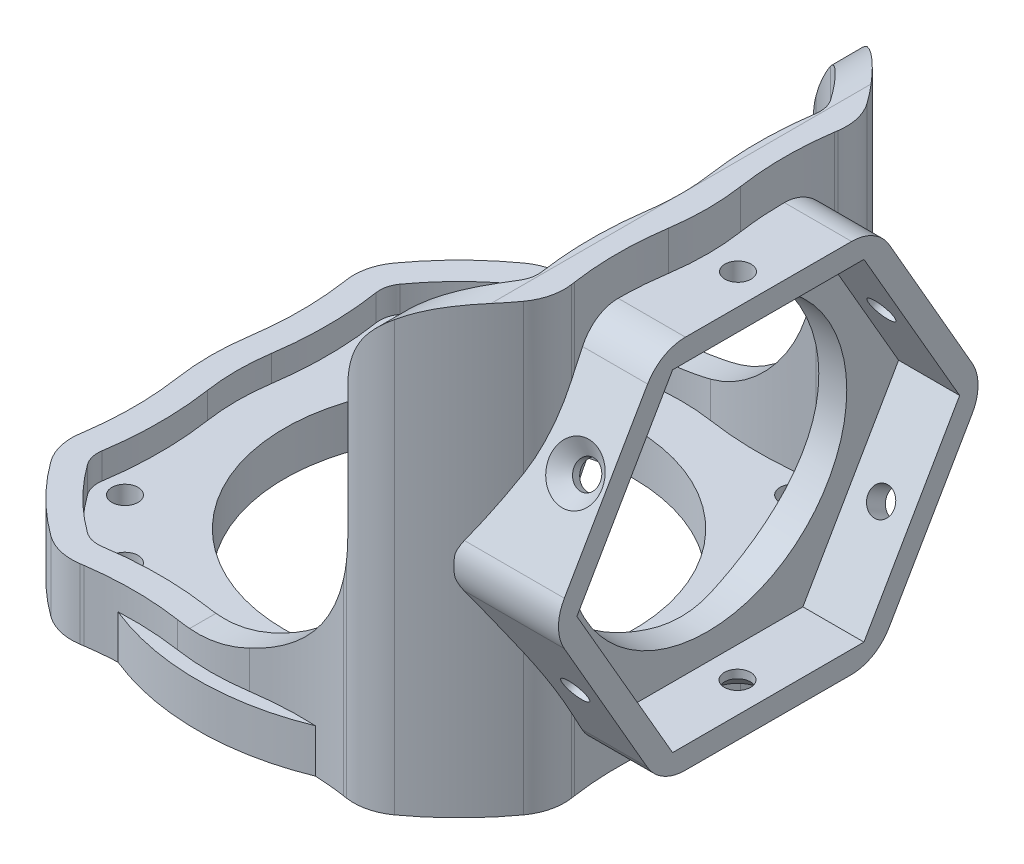
from build123d import *
from build123d.topology import SkipClean

# Parameters (mm, degrees)
SKETCH_1_R               = 30
SKETCH_1_R_2             = 20
SKETCH_1_R_3             = 1.5
EXTRUDE_1_DEPTH          = 5
EXTRUDE_2_DEPTH          = 46
EXTRUDE_2_DEPTH_BACK     = 5
CUT_EXTRUDE_1_DEPTH      = 67.340033162
CUT_EXTRUDE_1_DEPTH_BACK = 67.340033162
CUT_EXTRUDE_2_DEPTH      = 19
CUT_EXTRUDE_2_DEPTH_BACK = 22
SKETCH_4_R               = 16
CUT_EXTRUDE_3_DEPTH      = 67.340033239
EXTRUDE_4_DEPTH          = 7
EXTRUDE_4_DEPTH_BACK     = 5
SKETCH_5_R               = 16
CUT_EXTRUDE_4_REACH      = 70.976
CUT_EXTRUDE_5_DEPTH      = 7
SKETCH_10_R              = 1.5
CUT_EXTRUDE_6_DEPTH      = 78.090718091
SKETCH_11_R              = 1.5
CUT_EXTRUDE_7_DEPTH      = 76.948521446
SKETCH_12_R              = 1.5
CUT_EXTRUDE_8_DEPTH      = 67.432206651
EXTRUDE_5_DEPTH          = 5
CHAMFER_1_SIZE           = 1.55


with BuildPart() as part:
    # 草图1 → 凸台-拉伸1 (new body)
    with BuildSketch(Plane(origin=(0, 0, 0), x_dir=(1, 0, 0), z_dir=(0, 1, 0))):
        with Locations(Location((0, 0, 0), (0, 0, 270))):
            Circle(SKETCH_1_R)
        with Locations(Location((0, 0, 0), (0, 0, 270))):
            Circle(SKETCH_1_R_2, mode=Mode.SUBTRACT)
        with Locations(Location((-22.526681218, 15.773352, 0), (0, 0, 270))):
            Circle(SKETCH_1_R_3, mode=Mode.SUBTRACT)
        with Locations(Location((-15.773352, 22.526681218, 0), (0, 0, 270))):
            Circle(SKETCH_1_R_3, mode=Mode.SUBTRACT)
        with Locations(Location((22.526681218, 15.773352, 0), (0, 0, 90))):
            Circle(SKETCH_1_R_3, mode=Mode.SUBTRACT)
        with Locations(Location((15.773352, 22.526681218, 0), (0, 0, 90))):
            Circle(SKETCH_1_R_3, mode=Mode.SUBTRACT)
        with Locations(Location((22.526681218, -15.773352, 0), (0, 0, 270))):
            Circle(SKETCH_1_R_3, mode=Mode.SUBTRACT)
        with Locations(Location((15.773352, -22.526681218, 0), (0, 0, 270))):
            Circle(SKETCH_1_R_3, mode=Mode.SUBTRACT)
        with Locations(Location((-22.526681218, -15.773352, 0), (0, 0, 90))):
            Circle(SKETCH_1_R_3, mode=Mode.SUBTRACT)
        with Locations(Location((-15.773352, -22.526681218, 0), (0, 0, 90))):
            Circle(SKETCH_1_R_3, mode=Mode.SUBTRACT)
    extrude(amount=EXTRUDE_1_DEPTH)

    # 草图2 → 凸台-拉伸2 (add, two sides: drawn at the far end of the back side and taken through both)
    with BuildSketch(Plane(origin=(0, 5, 0), x_dir=(1, 0, 0), z_dir=(0, 1, 0)).offset(-EXTRUDE_2_DEPTH_BACK)):
        with BuildLine():
            ThreePointArc((28.144567873, 4.120724104), (28.45, 0), (28.144567873, -4.120724104))
            ThreePointArc((28.144567873, -4.120724104), (27.740305816, -9.505453332), (28.124116302, -14.891678929))
            ThreePointArc((28.124116302, -14.891678929), (28.151905564, -15.079780205), (28.180635292, -15.267740136))
            ThreePointArc((28.180635292, -15.267740136), (28.077159321, -17.585544722), (27.102069312, -19.690805952))
            ThreePointArc((27.102069312, -19.690805952), (23.68807717, -23.68807717), (19.690805952, -27.102069312))
            ThreePointArc((19.690805952, -27.102069312), (17.585544722, -28.077159321), (15.267740136, -28.180635292))
            ThreePointArc((15.267740136, -28.180635292), (15.079780205, -28.151905564), (14.891678929, -28.124116302))
            ThreePointArc((14.891678929, -28.124116302), (9.505453332, -27.740305816), (4.120724104, -28.144567873))
            ThreePointArc((4.120724104, -28.144567873), (0, -28.45), (-4.120724104, -28.144567873))
            ThreePointArc((-4.120724104, -28.144567873), (-9.505453332, -27.740305816), (-14.891678929, -28.124116302))
            ThreePointArc((-14.891678929, -28.124116302), (-15.079780205, -28.151905564), (-15.267740136, -28.180635292))
            ThreePointArc((-15.267740136, -28.180635292), (-17.585544722, -28.077159321), (-19.690805952, -27.102069312))
            ThreePointArc((-19.690805952, -27.102069312), (-23.68807717, -23.68807717), (-27.102069312, -19.690805952))
            ThreePointArc((-27.102069312, -19.690805952), (-28.077159321, -17.585544722), (-28.180635292, -15.267740136))
            ThreePointArc((-28.180635292, -15.267740136), (-28.151905564, -15.079780205), (-28.124116302, -14.891678929))
            ThreePointArc((-28.124116302, -14.891678929), (-27.740305816, -9.505453332), (-28.144567873, -4.120724104))
            ThreePointArc((-28.144567873, -4.120724104), (-28.45, 0), (-28.144567873, 4.120724104))
            ThreePointArc((-28.144567873, 4.120724104), (-27.740305816, 9.505453332), (-28.124116302, 14.891678929))
            ThreePointArc((-28.124116302, 14.891678929), (-28.151905564, 15.079780205), (-28.180635292, 15.267740136))
            ThreePointArc((-28.180635292, 15.267740136), (-28.077159321, 17.585544722), (-27.102069312, 19.690805952))
            ThreePointArc((-27.102069312, 19.690805952), (-23.68807717, 23.68807717), (-19.690805952, 27.102069312))
            ThreePointArc((-19.690805952, 27.102069312), (-17.585544722, 28.077159321), (-15.267740136, 28.180635292))
            ThreePointArc((-15.267740136, 28.180635292), (-15.079780205, 28.151905564), (-14.891678929, 28.124116302))
            ThreePointArc((-14.891678929, 28.124116302), (-9.505453332, 27.740305816), (-4.120724104, 28.144567873))
            ThreePointArc((-4.120724104, 28.144567873), (0, 28.45), (4.120724104, 28.144567873))
            ThreePointArc((4.120724104, 28.144567873), (9.505453332, 27.740305816), (14.891678929, 28.124116302))
            ThreePointArc((14.891678929, 28.124116302), (15.079780205, 28.151905564), (15.267740136, 28.180635292))
            ThreePointArc((15.267740136, 28.180635292), (17.585544722, 28.077159321), (19.690805952, 27.102069312))
            ThreePointArc((19.690805952, 27.102069312), (23.68807717, 23.68807717), (27.102069312, 19.690805952))
            ThreePointArc((27.102069312, 19.690805952), (28.077159321, 17.585544722), (28.180635292, 15.267740136))
            ThreePointArc((28.180635292, 15.267740136), (28.151905564, 15.079780205), (28.124116302, 14.891678929))
            ThreePointArc((28.124116302, 14.891678929), (27.740305816, 9.505453332), (28.144567873, 4.120724104))
        make_face()
        with BuildLine():
            ThreePointArc((25.177351285, -3.678428135), (25.45, 0), (25.177351285, 3.678428135))
            ThreePointArc((25.177351285, 3.678428135), (24.910544975, 5.888504903), (24.767101806, 8.110001917))
            ThreePointArc((24.767101806, 8.110001917), (24.808867462, 11.917834471), (25.212544446, 15.70443955))
            ThreePointArc((25.212544446, 15.70443955), (25.163933297, 16.869177817), (24.675018328, 17.927450195))
            ThreePointArc((24.675018328, 17.927450195), (21.566756826, 21.566756826), (17.927450195, 24.675018328))
            ThreePointArc((17.927450195, 24.675018328), (16.869177817, 25.163933297), (15.70443955, 25.212544446))
            ThreePointArc((15.70443955, 25.212544446), (11.917834471, 24.808867462), (8.110001917, 24.767101806))
            ThreePointArc((8.110001917, 24.767101806), (5.888504903, 24.910544975), (3.678428135, 25.177351285))
            ThreePointArc((3.678428135, 25.177351285), (0, 25.45), (-3.678428135, 25.177351285))
            ThreePointArc((-3.678428135, 25.177351285), (-5.888504903, 24.910544975), (-8.110001917, 24.767101806))
            ThreePointArc((-8.110001917, 24.767101806), (-11.917834471, 24.808867462), (-15.70443955, 25.212544446))
            ThreePointArc((-15.70443955, 25.212544446), (-16.869177817, 25.163933297), (-17.927450195, 24.675018328))
            ThreePointArc((-17.927450195, 24.675018328), (-21.566756826, 21.566756826), (-24.675018328, 17.927450195))
            ThreePointArc((-24.675018328, 17.927450195), (-25.163933297, 16.869177817), (-25.212544446, 15.70443955))
            ThreePointArc((-25.212544446, 15.70443955), (-24.808867462, 11.917834471), (-24.767101806, 8.110001917))
            ThreePointArc((-24.767101806, 8.110001917), (-24.910544975, 5.888504903), (-25.177351285, 3.678428135))
            ThreePointArc((-25.177351285, 3.678428135), (-25.45, 0), (-25.177351285, -3.678428135))
            ThreePointArc((-25.177351285, -3.678428135), (-24.910544975, -5.888504903), (-24.767101806, -8.110001917))
            ThreePointArc((-24.767101806, -8.110001917), (-24.808867462, -11.917834471), (-25.212544446, -15.70443955))
            ThreePointArc((-25.212544446, -15.70443955), (-25.163933297, -16.869177817), (-24.675018328, -17.927450195))
            ThreePointArc((-24.675018328, -17.927450195), (-21.566756826, -21.566756826), (-17.927450195, -24.675018328))
            ThreePointArc((-17.927450195, -24.675018328), (-16.869177817, -25.163933297), (-15.70443955, -25.212544446))
            ThreePointArc((-15.70443955, -25.212544446), (-11.917834471, -24.808867462), (-8.110001917, -24.767101806))
            ThreePointArc((-8.110001917, -24.767101806), (-5.888504903, -24.910544975), (-3.678428135, -25.177351285))
            ThreePointArc((-3.678428135, -25.177351285), (0, -25.45), (3.678428135, -25.177351285))
            ThreePointArc((3.678428135, -25.177351285), (5.888504903, -24.910544975), (8.110001917, -24.767101806))
            ThreePointArc((8.110001917, -24.767101806), (11.917834471, -24.808867462), (15.70443955, -25.212544446))
            ThreePointArc((15.70443955, -25.212544446), (16.869177817, -25.163933297), (17.927450195, -24.675018328))
            ThreePointArc((17.927450195, -24.675018328), (21.566756826, -21.566756826), (24.675018328, -17.927450195))
            ThreePointArc((24.675018328, -17.927450195), (25.163933297, -16.869177817), (25.212544446, -15.70443955))
            ThreePointArc((25.212544446, -15.70443955), (24.808867462, -11.917834471), (24.767101806, -8.110001917))
            ThreePointArc((24.767101806, -8.110001917), (24.910544975, -5.888504903), (25.177351285, -3.678428135))
        make_face(mode=Mode.SUBTRACT)
    extrude(amount=EXTRUDE_2_DEPTH + EXTRUDE_2_DEPTH_BACK)

    # 草图3 → 切除-拉伸1 (cut, two sides: drawn at the far end of the back side and taken through both)
    with BuildSketch(Plane.XY.offset(-CUT_EXTRUDE_1_DEPTH_BACK)):
        with BuildLine():
            Line((-30.727261275, 8), (-30.727261275, -1.751360646))
            Line((-30.727261275, -1.751360646), (-34.309552413, -1.751360646))
            Line((-34.309552413, -1.751360646), (-34.309552413, 55.881753359))
            Line((-34.309552413, 55.881753359), (36.225745412, 55.881753359))
            Line((36.225745412, 55.881753359), (36.225745412, -1.751360646))
            Line((36.225745412, -1.751360646), (28.45, -1.751360646))
            Line((28.45, -1.751360646), (28.45, 51))
            Line((28.45, 51), (25.45, 51))
            ThreePointArc((25.45, 51), (18.378932188, 48.071067812), (15.45, 41))
            Line((15.45, 41), (15.45, 26))
            ThreePointArc((15.45, 26), (10.177922061, 13.272077939), (-2.55, 8))
            Line((-2.55, 8), (-30.727261275, 8))
        make_face()
    extrude(amount=CUT_EXTRUDE_1_DEPTH + CUT_EXTRUDE_1_DEPTH_BACK, mode=Mode.SUBTRACT)

    # 草图4 → 切除-拉伸2 (cut, two sides: drawn at the far end of the back side and taken through both)
    with BuildSketch(Plane(origin=(28.45, 0, 0), x_dir=(0, 0, -1), z_dir=(1, 0, 0)).offset(-CUT_EXTRUDE_2_DEPTH_BACK)):
        with Locations(Location((0, 25, 0), (0, 0, 168.970098929))):
            Circle(SKETCH_4_R)
    extrude(amount=CUT_EXTRUDE_2_DEPTH + CUT_EXTRUDE_2_DEPTH_BACK, mode=Mode.SUBTRACT)

    # 草图7 → 切除-拉伸3 (cut, through all)
    with SkipClean():  # the faces are left unmerged after this step: merging them gives an invalid solid
        with BuildSketch(Plane(origin=(0, 51, 0), x_dir=(1, 0, 0), z_dir=(0, 1, 0))):
            with BuildLine():
                Line((28.124116302, -14.891678929), (31.102669692, -14.083507972))
                Line((31.102669692, -14.083507972), (31.102669692, 14.25157685))
                Line((31.102669692, 14.25157685), (28.124116302, 14.891678929))
                ThreePointArc((28.124116302, 14.891678929), (27.740305816, 9.505453332), (28.144567873, 4.120724104))
                ThreePointArc((28.144567873, 4.120724104), (28.45, 0), (28.144567873, -4.120724104))
                ThreePointArc((28.144567873, -4.120724104), (27.740305816, -9.505453332), (28.124116302, -14.891678929))
            make_face()
        extrude(amount=-CUT_EXTRUDE_3_DEPTH, mode=Mode.SUBTRACT)

    # 草图5 → 凸台-拉伸4 (add, two sides: drawn at the far end of the back side and taken through both)
    with SkipClean():  # the faces are left unmerged after this step: merging them gives an invalid solid
        with BuildSketch(Plane(origin=(28.45, 0, 0), x_dir=(0, 0, -1), z_dir=(1, 0, 0)).offset(-EXTRUDE_4_DEPTH_BACK)):
            with BuildLine():
                Line((13.830781561, 5.981338601), (23.379294616, 22.468482029))
                ThreePointArc((23.379294616, 22.468482029), (24.05253703, 24.967576758), (23.386034698, 27.468477486))
                Line((23.386034698, 27.468477486), (13.882006181, 43.981304075))
                ThreePointArc((13.882006181, 43.981304075), (12.054347866, 45.813896472), (9.555253137, 46.487138885))
                Line((9.555253137, 46.487138885), (-9.497288435, 46.512822046))
                ThreePointArc((-9.497288435, 46.512822046), (-11.998189164, 45.846319714), (-13.830781561, 44.018661399))
                Line((-13.830781561, 44.018661399), (-23.379294616, 27.531517971))
                ThreePointArc((-23.379294616, 27.531517971), (-24.05253703, 25.032423242), (-23.386034698, 22.531522514))
                Line((-23.386034698, 22.531522514), (-13.882006181, 6.018695925))
                ThreePointArc((-13.882006181, 6.018695925), (-12.054347866, 4.186103528), (-9.555253137, 3.512861115))
                Line((-9.555253137, 3.512861115), (9.497288435, 3.487177954))
                ThreePointArc((9.497288435, 3.487177954), (11.998189164, 4.153680286), (13.830781561, 5.981338601))
            make_face()
            with Locations((0, 25)):
                Circle(SKETCH_5_R, mode=Mode.SUBTRACT)
        extrude(amount=EXTRUDE_4_DEPTH + EXTRUDE_4_DEPTH_BACK)

    # 切除-拉伸4: up to this face of the body (flat: up to its plane)
    cut_extrude_4_end = Plane(part.part.faces().sort_by_distance((0, 5, 28.795836719))[0])
    # 草图8 → 切除-拉伸4 (cut, up to the picked face)
    with BuildSketch(Plane(origin=(0, 51, 0), x_dir=(1, 0, 0), z_dir=(0, 1, 0)), mode=Mode.PRIVATE) as cut_extrude_4_sk1:
        with BuildLine():
            Line((17.927450195, -24.675018328), (17.927450195, 24.675018328))
            ThreePointArc((17.927450195, 24.675018328), (21.566757047, 21.566757047), (24.675018328, 17.927450195))
            ThreePointArc((24.675018328, 17.927450195), (25.163933221, 16.869177798), (25.212544446, 15.70443955))
            ThreePointArc((25.212544446, 15.70443955), (24.740410789, 9.692764009), (25.177351285, 3.678428135))
            ThreePointArc((25.177351285, 3.678428135), (25.381744338, 1.844259386), (25.45, 0))
            ThreePointArc((25.45, 0), (25.381744458, -1.844259395), (25.177351285, -3.678428135))
            ThreePointArc((25.177351285, -3.678428135), (24.740410395, -9.69276401), (25.212544446, -15.70443955))
            ThreePointArc((25.212544446, -15.70443955), (25.163933297, -16.869177817), (24.675018328, -17.927450195))
            ThreePointArc((24.675018328, -17.927450195), (21.566756826, -21.566756826), (17.927450195, -24.675018328))
        make_face()
    cut_extrude_4_tool1 = split(extrude(cut_extrude_4_sk1.sketch, amount=-CUT_EXTRUDE_4_REACH, mode=Mode.PRIVATE), bisect_by=cut_extrude_4_end, keep=Keep.BOTH, mode=Mode.PRIVATE)
    add(cut_extrude_4_tool1.solids().sort_by(Axis((21.279019, 51, 0), (0, -1, 0)))[0], mode=Mode.SUBTRACT)

    # 草图9 → 切除-拉伸5 (cut)
    with BuildSketch(Plane(origin=(35.45, 0, 0), x_dir=(0, 0, -1), z_dir=(1, 0, 0))):
        Polygon((10.969655115, 6), (21.939310229, 25), (10.969655115, 44), (-10.969655115, 44), (-21.939310229, 25), (-10.969655115, 6), align=None)
    extrude(amount=-CUT_EXTRUDE_5_DEPTH, mode=Mode.SUBTRACT)

    # 草图10 → 切除-拉伸6 (cut, through all)
    with SkipClean():  # the faces are left unmerged after this step: merging them gives an invalid solid
        with BuildSketch(Plane(origin=(0, 17.054297782, 29.447166482), x_dir=(1, 0, 0), z_dir=(0, 0.5011669620932969, 0.8653506087743718))):
            with Locations(Location((31.95, 21.633765219, 0), (0, 0, 90))):
                Circle(SKETCH_10_R)
        extrude(amount=-CUT_EXTRUDE_6_DEPTH, mode=Mode.SUBTRACT)

    # 草图11 → 切除-拉伸7 (cut, through all)
    with SkipClean():  # the faces are left unmerged after this step: merging them gives an invalid solid
        with BuildSketch(Plane(origin=(0, -4.504053449, 7.825592423), x_dir=(1, 0, 0), z_dir=(0, -0.4988321293322869, 0.8666986250974538))):
            with Locations(Location((31.95, 21.667465627, 0), (0, 0, 90))):
                Circle(SKETCH_11_R)
        extrude(amount=-CUT_EXTRUDE_7_DEPTH, mode=Mode.SUBTRACT)

    # 草图12 → 切除-拉伸8 (cut, through all)
    with SkipClean():  # the faces are left unmerged after this step: merging them gives an invalid solid
        with BuildSketch(Plane(origin=(0, 3.499974106, -0.004718027), x_dir=(1, 0, 0), z_dir=(0, -0.9999990914255836, 0.0013480163230821984))):
            with Locations(Location((31.95, 0.033700408, 0), (0, 0, 90))):
                Circle(SKETCH_12_R)
        extrude(amount=-CUT_EXTRUDE_8_DEPTH, mode=Mode.SUBTRACT)

    # 草图13 → 凸台-拉伸5 (add)
    with SkipClean():  # the faces are left unmerged after this step: merging them gives an invalid solid
        with BuildSketch(Plane.XZ):
            Polygon((-14.090433806, 25.674288062), (-15.603983364, 24.794317389), (-17.36392471, 24.019943197), (-20.883807402, 20.464861678), (-23.981304171, 16.839382505), (-26.019748348, 14.453476252), (-25.565251383, 18.652122091), (-20.883807402, 24.131539478), (-17.283661607, 26.224647498), align=None)
            Polygon((-21.467621163, -19.574447055), (-18.638124574, -22.375928826), (-16.346665577, -24.333680202), (-15.31024745, -25.612027505), (-16.346665577, -26.452301922), (-20.653026975, -24.030756435), (-24.342659472, -20.101537412), (-25.792499865, -17.607811936), (-26.019748348, -15.261889591), (-25.013665133, -15.43529012), (-23.31784965, -17.837389779), align=None)
            Polygon((23.762340214, -17.452588245), (24.807891272, -16.174692506), (25.9115285, -15.632554921), (26.240683463, -17.123433282), (25.040235952, -19.427518022), (22.561892702, -22.002671554), (19.28970513, -24.461652747), (16.733913654, -25.991255222), (14.73962182, -25.758910542), (15.339678893, -24.607188095), (16.954407578, -24.098682377), (18.775001176, -22.206971841), (22.561892702, -18.904742492), align=None)
            Polygon((14.997646513, 25.500467238), (16.954407578, 24.437704778), (19.001983639, 22.748671583), (20.709994735, 20.718036169), (22.561892702, 19.010025073), (24.050105323, 16.839382505), (25.801768383, 15.223818366), (26.061762836, 16.523920033), (24.242752959, 19.252321692), (22.392196232, 21.452428023), (19.855989187, 23.791579451), (17.814676775, 25.674288062), (15.976027046, 26.224647498), align=None)
        extrude(amount=-EXTRUDE_5_DEPTH)

    # 倒角1
    chamfer_1_edges = [part.edges().sort_by_distance(p)[0] for p in [
        (-15.773352, 0, -24.026681218),
        (22.526681218, 0, -14.273352),
        (15.773352, 0, -21.026681218),
        (22.526681218, 0, 14.273352),
        (15.773352, 0, 21.026681218),
        (-22.526681218, 0, 17.273352),
        (-15.773352, 0, 24.026681218),
        (31.95, 34.477063772, 19.356788532),
        (31.95, 34.424842843, -19.382268634),
        (31.95, 3.49799751, -1.471016286),
        (-22.526681218, 0, -17.273352),
    ]]
    chamfer(chamfer_1_edges, length=CHAMFER_1_SIZE)


solid = part.part
